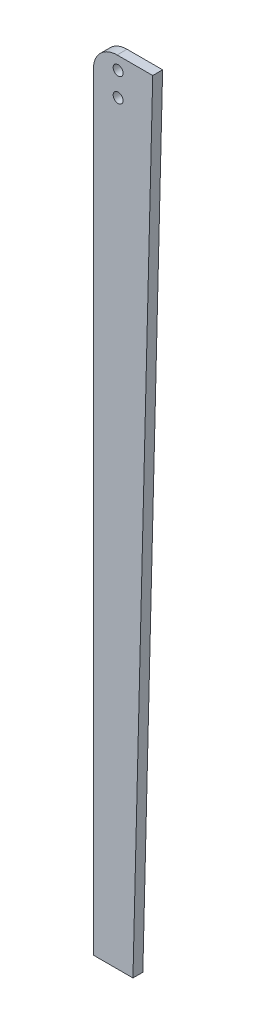
from build123d import *

# Parameters (mm, degrees)
SKETCH1_R           = 1.5875
BOSS_EXTRUDE1_DEPTH = 3.175


with BuildPart() as part:
    # Sketch1 → Boss-Extrude1 (new body)
    with BuildSketch(Plane.XY):
        with BuildLine():
            Line((-0.3175, 4.1275), (11.1125, 4.1275))
            Line((11.1125, 4.1275), (4.7625, -249.8725))
            Line((4.7625, -249.8725), (-7.9375, -249.8725))
            Line((-7.9375, -249.8725), (-7.9375, -3.4925))
            ThreePointArc((-7.9375, -3.4925), (-5.705653673, 1.895653673), (-0.3175, 4.1275))
        make_face()
        Circle(SKETCH1_R, mode=Mode.SUBTRACT)
        with Locations((0, -7.62)):
            Circle(SKETCH1_R, mode=Mode.SUBTRACT)
    extrude(amount=BOSS_EXTRUDE1_DEPTH)


solid = part.part
